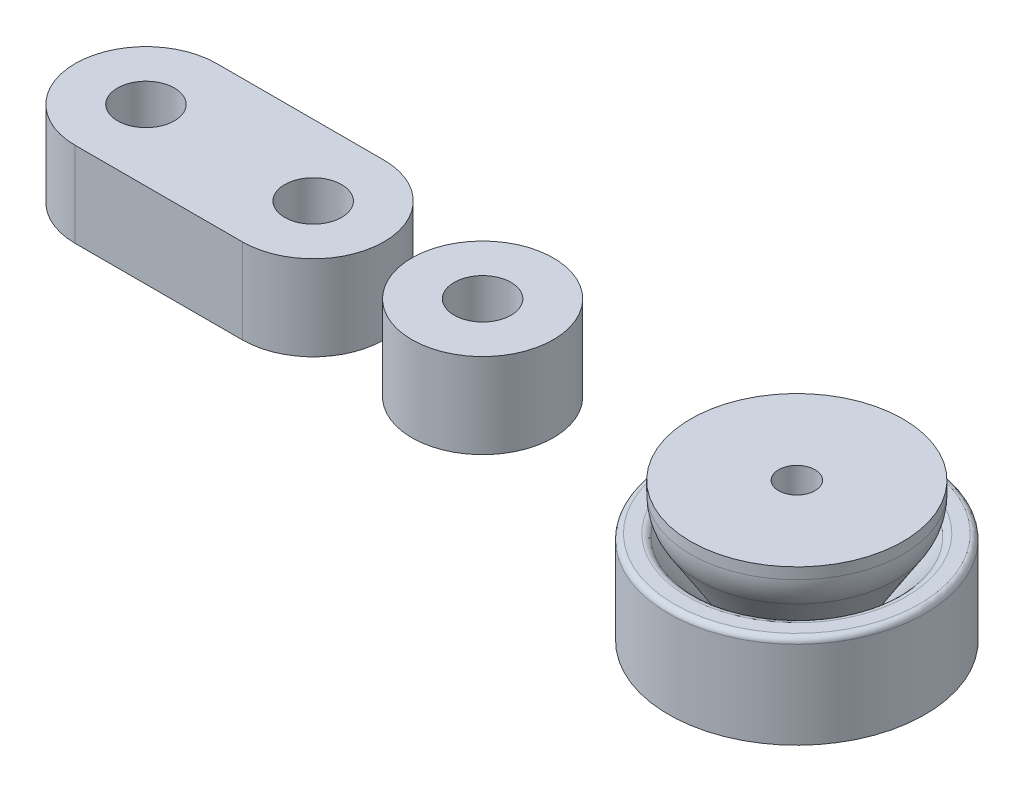
from build123d import *

# Parameters (mm, degrees)
CSK_FOR_4_FLAT_HEAD_SOCKET_CAP_SCREW1_D           = 3.2639
CSK_FOR_4_FLAT_HEAD_SOCKET_CAP_SCREW1_DEPTH       = 4.06
CSK_FOR_4_FLAT_HEAD_SOCKET_CAP_SCREW1_CSINK_D     = 6.477
CSK_FOR_4_FLAT_HEAD_SOCKET_CAP_SCREW1_CSINK_ANGLE = 82
CSK_FOR_4_FLAT_HEAD_SOCKET_CAP_SCREW1_TIP         = 0.980574487
BOSS_EXTRUDE2_START                               = 4.8387
SKETCH5_R                                         = 6.35
BOSS_EXTRUDE2_DEPTH                               = 7.62
BOSS_EXTRUDE2_2_DEPTH                             = 7.62
CSK_FOR_10_FLAT_HEAD_SOCKET_CAP_SCR_2_COUNT       = 2
CSK_FOR_10_FLAT_HEAD_SOCKET_CAP_SCR_2_PITCH       = 15.198690223
CSK_FOR_10_FLAT_HEAD_SOCKET_CAP_SCR_3_COUNT       = 2
CSK_FOR_10_FLAT_HEAD_SOCKET_CAP_SCR_3_PITCH       = 30.198690223


with BuildPart() as part:
    # Sketch1 → Revolve1 (revolve)
    with BuildSketch(Plane.XY):
        with BuildLine():
            Line((-3.2385, 3.8387), (-3.2385, 7.3787))
            Line((-3.2385, 7.3787), (-1.63195, 9.226824365))
            Line((-1.63195, 9.226824365), (-1.63195, 12.4587))
            Line((-1.63195, 12.4587), (-9.525, 12.4587))
            Line((-9.525, 12.4587), (-9.525, 11.4587))
            ThreePointArc((-9.525, 11.4587), (-9.349730987, 10.224889293), (-8.83779156, 9.0887))
            Line((-8.83779156, 9.0887), (-5.660943195, 4.07122711))
            ThreePointArc((-5.660943195, 4.07122711), (-5.479605325, 3.90067235), (-5.2385, 3.8387))
            Line((-5.2385, 3.8387), (-3.2385, 3.8387))
        make_face()
        with BuildLine():
            Line((0, 2.8387), (-4.24186361, 2.8387))
            ThreePointArc((-4.24186361, 2.8387), (-4.831651168, 2.969884174), (-5.310225652, 3.3387))
            Line((-5.310225652, 3.3387), (-9.257149739, 8.069186786))
            ThreePointArc((-9.257149739, 8.069186786), (-9.515114034, 8.267988263), (-9.833025114, 8.3387))
            Line((-9.833025114, 8.3387), (-11, 8.3387))
            ThreePointArc((-11, 8.3387), (-11.353553391, 8.192253391), (-11.5, 7.8387))
            Line((-11.5, 7.8387), (-11.5, 0))
            Line((-11.5, 0), (0, 0))
            Line((0, 0), (0, 2.8387))
        make_face()
    revolve(axis=Axis((0, 0, 0), (0, 1, 0)))

    # CSK for #4 Flat Head Socket Cap Screw1
    with Locations(Plane(origin=(0, 2.8387, 0), x_dir=(1, 0, 0), z_dir=(0, 1, 0))):
        with Locations((0, 0)):
            CounterSinkHole(CSK_FOR_4_FLAT_HEAD_SOCKET_CAP_SCREW1_D / 2, CSK_FOR_4_FLAT_HEAD_SOCKET_CAP_SCREW1_CSINK_D / 2, depth=CSK_FOR_4_FLAT_HEAD_SOCKET_CAP_SCREW1_DEPTH, counter_sink_angle=CSK_FOR_4_FLAT_HEAD_SOCKET_CAP_SCREW1_CSINK_ANGLE)
            with Locations((0, 0, -(CSK_FOR_4_FLAT_HEAD_SOCKET_CAP_SCREW1_DEPTH + CSK_FOR_4_FLAT_HEAD_SOCKET_CAP_SCREW1_TIP / 2))):  # 118° drill point
                Cone(0, CSK_FOR_4_FLAT_HEAD_SOCKET_CAP_SCREW1_D / 2, CSK_FOR_4_FLAT_HEAD_SOCKET_CAP_SCREW1_TIP, mode=Mode.SUBTRACT)


with BuildPart() as body_2:
    # Sketch5 → Boss-Extrude2 (new body)
    with BuildSketch(Plane(origin=(0, 0, 0), x_dir=(1, 0, 0), z_dir=(0, 1, 0)).offset(BOSS_EXTRUDE2_START)):
        with Locations((-28.181991906, 0)):
            Circle(SKETCH5_R)
    extrude(amount=BOSS_EXTRUDE2_DEPTH)

    # Sketch7 → CSK for #10 Flat Head Socket Cap Screw1 (revolve, cut)
    with BuildSketch(Plane(origin=(-28.181991906, 4.8387, 0), x_dir=(0, 0, -1), z_dir=(1, 0, 0))):
        Polygon((0, 0), (0, 7.62), (2.5527, 7.62), (2.5527, 2.761229288), (4.953, 0), align=None)
    csk_for_10_flat_head_socket_cap_screw1 = revolve(axis=Axis((-28.181991906, -1.5113, 0), (0, 1, 0)), mode=Mode.SUBTRACT)


with BuildPart() as body_3:
    # Sketch5 → Boss-Extrude2 2 (new body)
    with BuildSketch(Plane(origin=(0, 0, 0), x_dir=(1, 0, 0), z_dir=(0, 1, 0)).offset(BOSS_EXTRUDE2_START)):
        with BuildLine():
            Line((-58.38068213, 6.35), (-43.38068213, 6.35))
            ThreePointArc((-43.38068213, 6.35), (-37.03068213, 0), (-43.38068213, -6.35))
            Line((-43.38068213, -6.35), (-58.38068213, -6.35))
            ThreePointArc((-58.38068213, -6.35), (-64.73068213, 0), (-58.38068213, 6.35))
        make_face()
    extrude(amount=BOSS_EXTRUDE2_2_DEPTH)

    # CSK for _10 Flat Head Socket Cap Scr 2: CSK for #10 Flat Head Socket Cap Screw1 ×2
    with Locations(*[(-i * CSK_FOR_10_FLAT_HEAD_SOCKET_CAP_SCR_2_PITCH, 0, 0) for i in range(1, CSK_FOR_10_FLAT_HEAD_SOCKET_CAP_SCR_2_COUNT)]):
        add(csk_for_10_flat_head_socket_cap_screw1, mode=Mode.SUBTRACT)

    # CSK for _10 Flat Head Socket Cap Scr 3: CSK for #10 Flat Head Socket Cap Screw1 ×2
    with Locations(*[(-i * CSK_FOR_10_FLAT_HEAD_SOCKET_CAP_SCR_3_PITCH, 0, 0) for i in range(1, CSK_FOR_10_FLAT_HEAD_SOCKET_CAP_SCR_3_COUNT)]):
        add(csk_for_10_flat_head_socket_cap_screw1, mode=Mode.SUBTRACT)


solid = Compound([part.part, body_2.part, body_3.part])
